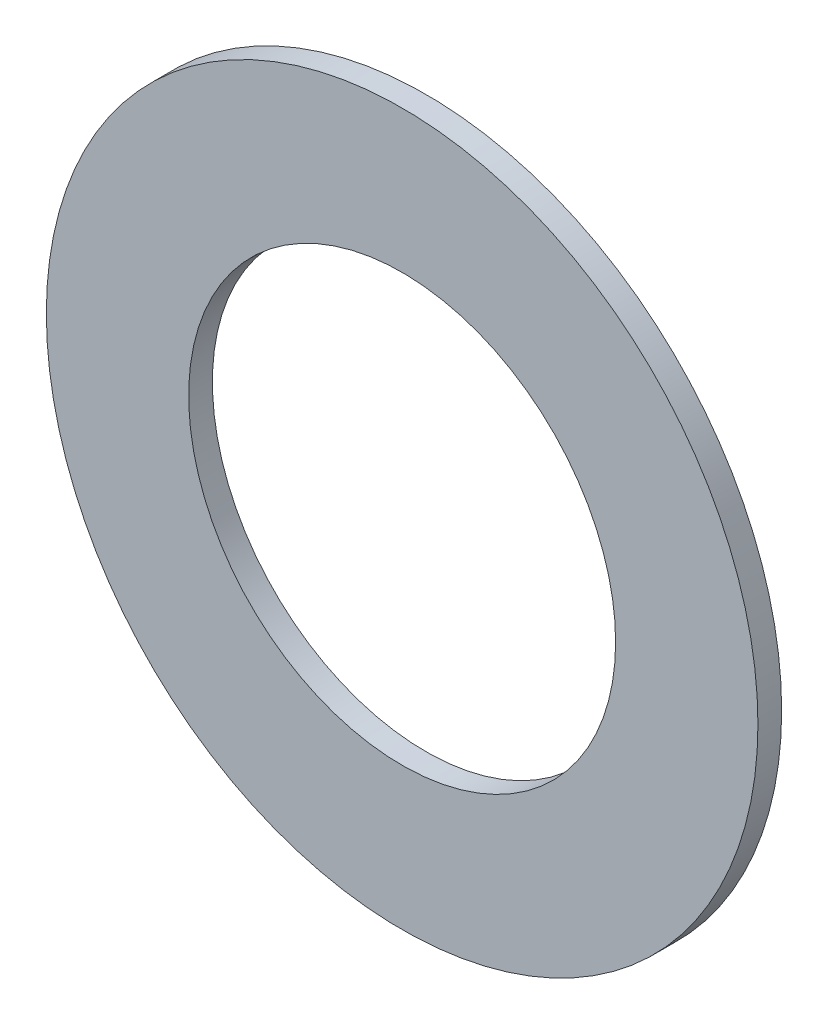
from build123d import *

# Parameters (mm, degrees)
SKETCH1_R           = 3.75
SKETCH1_R_2         = 2.25
BOSS_EXTRUDE1_DEPTH = 0.25


with BuildPart() as part:
    # Sketch1 → Boss-Extrude1 (new body)
    with BuildSketch(Plane.XY):
        Circle(SKETCH1_R)
        Circle(SKETCH1_R_2, mode=Mode.SUBTRACT)
    extrude(amount=BOSS_EXTRUDE1_DEPTH)


solid = part.part
